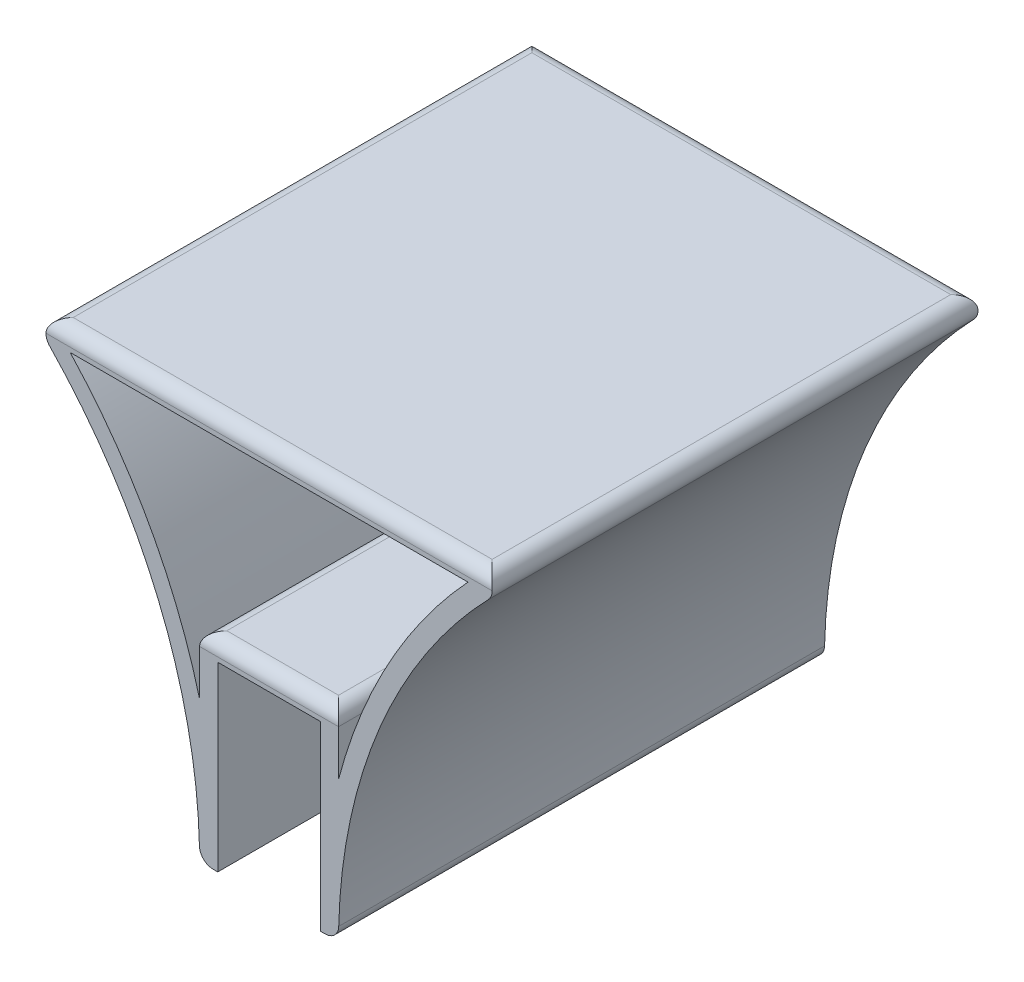
from build123d import *

# Parameters (mm, degrees)
BOSS_EXTRU_1_DEPTH = 53.5
CONG_1_R           = 3


with BuildPart() as part:
    # Esquisse1 → Boss.-Extru.1 (new body, symmetric)
    with BuildSketch(Plane.XY):
        with BuildLine():
            Line((-11.3, 0), (11.3, 0))
            Line((11.3, 0), (11.3, -40))
            Line((11.3, -40), (15.3, -40))
            ThreePointArc((15.3, -40), (25.272141163, 7.430887623), (53.5, 46.830388705))
            Line((53.5, 46.830388705), (-53.5, 46.830388705))
            ThreePointArc((-53.5, 46.830388705), (-25.272141163, 7.430887623), (-15.3, -40))
            Line((-15.3, -40), (-11.3, -40))
            Line((-11.3, -40), (-11.3, 0))
        make_face()
        with BuildLine():
            Line((43.806234565, 42.830388705), (-43.806234565, 42.830388705))
            ThreePointArc((-43.806234565, 42.830388705), (-26.353615228, 18.651434723), (-15.3, -9.043931817))
            Line((-15.3, -9.043931817), (-15.3, 4))
            Line((-15.3, 4), (15.3, 4))
            Line((15.3, 4), (15.3, -9.043931817))
            ThreePointArc((15.3, -9.043931817), (26.353615228, 18.651434723), (43.806234565, 42.830388705))
        make_face(mode=Mode.SUBTRACT)
    extrude(amount=BOSS_EXTRU_1_DEPTH, both=True)

    # Congé1
    cong_1_edges = [part.edges().sort_by_distance(p)[0] for p in [
        (0, 46.830388705, 53.5),
        (-15.3, -40, 0),
        (-53.5, 46.830388705, 0),
        (53.5, 46.830388705, 0),
        (15.3, -40, 0),
        (0, 46.830388705, -53.5),
        (0, 4, -53.5),
        (15.3, 4, 0),
        (-15.3, 4, 0),
        (0, 4, 53.5),
    ]]
    fillet(cong_1_edges, radius=CONG_1_R)


solid = part.part
